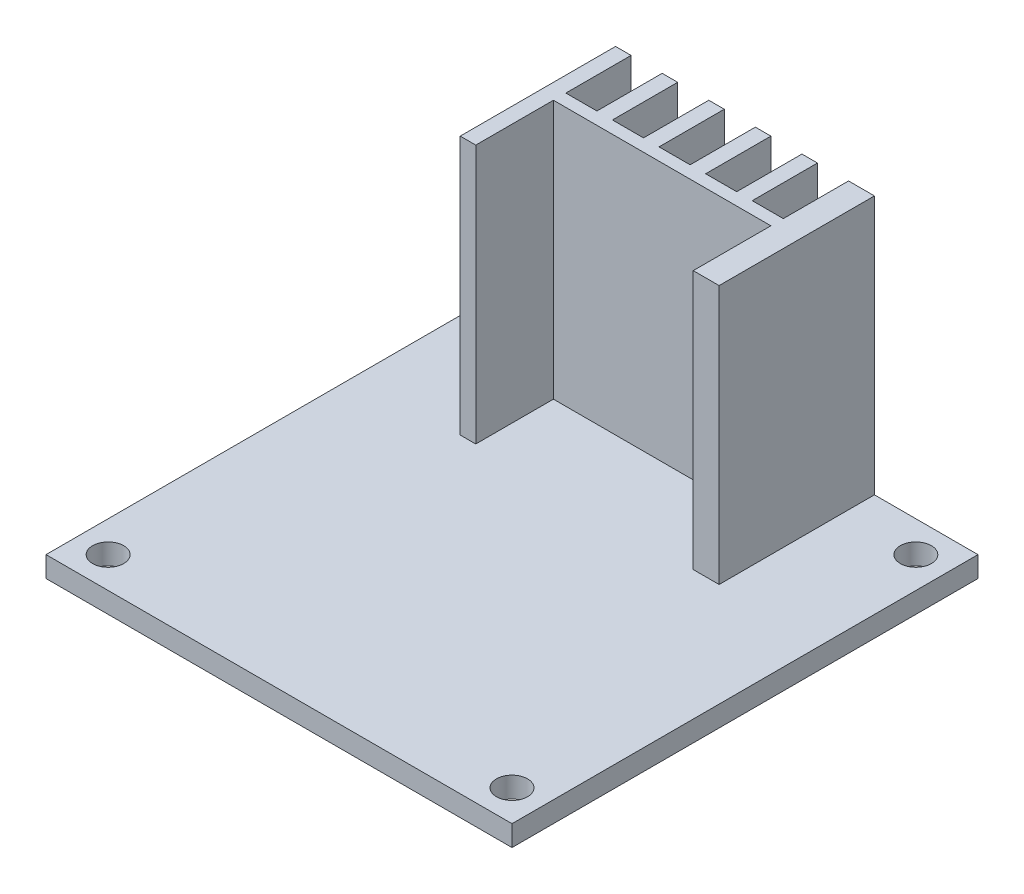
from build123d import *

# Parameters (mm, degrees)
SKETCH1_W           = 45
SKETCH1_H           = 45
SKETCH1_R           = 1.5
BOSS_EXTRUDE1_DEPTH = 2
BOSS_EXTRUDE2_DEPTH = 25


with BuildPart() as part:
    # Sketch1 → Boss-Extrude1 (new body)
    with BuildSketch(Plane(origin=(0, 0, 0), x_dir=(1, 0, 0), z_dir=(0, 1, 0))):
        Rectangle(SKETCH1_W, SKETCH1_H)
        with Locations((-19.5, 19.5)):
            Circle(SKETCH1_R, mode=Mode.SUBTRACT)
        with Locations((19.5, 19.5)):
            Circle(SKETCH1_R, mode=Mode.SUBTRACT)
        with Locations((-19.5, -19.5)):
            Circle(SKETCH1_R, mode=Mode.SUBTRACT)
        with Locations((19.5, -19.5)):
            Circle(SKETCH1_R, mode=Mode.SUBTRACT)
    extrude(amount=BOSS_EXTRUDE1_DEPTH)

    # Sketch2 → Boss-Extrude2 (add)
    with BuildSketch(Plane(origin=(0, 2, 0), x_dir=(1, 0, 0), z_dir=(0, 1, 0))):
        Polygon((10, 7.5), (12.5, 7.5), (12.5, 22.5), (10, 22.5), (10, 16.2), (7, 16.2), (7, 22.5), (5.5, 22.5), (5.5, 16.2), (2.5, 16.2), (2.5, 22.5), (1, 22.5), (1, 16.2), (-2, 16.2), (-2, 22.5), (-3.5, 22.5), (-3.5, 16.2), (-6.5, 16.2), (-6.5, 22.5), (-8, 22.5), (-8, 16.2), (-11, 16.2), (-11, 22.5), (-12.5, 22.5), (-12.5, 7.5), (-11, 7.5), (-11, 15), (10, 15), align=None)
    extrude(amount=BOSS_EXTRUDE2_DEPTH)


solid = part.part
